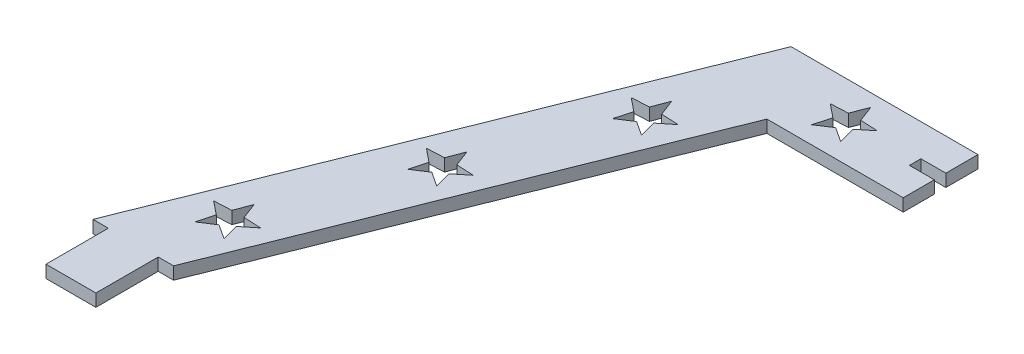
from build123d import *

# Parameters (mm, degrees)
BOSS_EXTRUDE1_DEPTH = 3.175


with BuildPart() as part:
    # Sketch1 → Boss-Extrude1 (new body)
    with BuildSketch(Plane(origin=(0, 0, 0), x_dir=(1, 0, 0), z_dir=(0, 1, 0))):
        Polygon((98.425, 127), (98.425, 118.8085), (92.075, 118.8085), (92.075, 115.8875), (98.425, 115.8875), (98.425, 107.95), (63.697477915, 107.95), (20.517477915, 0), (16.610957915, 0), (16.610957915, -15.875), (3.90652, -15.875), (3.90652, 0), (0, 0), (50.8, 127), align=None)
        Polygon((74.356304753, 123.754225326), (72.787834938, 119.633813496), (68.38440659, 119.415387337), (71.818467282, 116.65040662), (70.665468711, 112.395), (74.356304753, 114.806559768), (78.047140796, 112.395), (76.894142225, 116.65040662), (80.328202917, 119.415387337), (75.924774569, 119.633813496), align=None, mode=Mode.SUBTRACT)
        Polygon((47.649827384, 99.756946391), (46.081357569, 95.636534562), (41.67792922, 95.418108402), (45.111989912, 92.653127685), (43.958991341, 88.397721065), (47.649827384, 90.809280833), (51.340663426, 88.397721065), (50.187664855, 92.653127685), (53.621725547, 95.418108402), (49.218297199, 95.636534562), align=None, mode=Mode.SUBTRACT)
        Polygon((32.742653477, 62.489011624), (31.174183662, 58.368599795), (26.770755314, 58.150173636), (30.204816006, 55.385192919), (29.051817435, 51.129786299), (32.742653477, 53.541346066), (36.433489519, 51.129786299), (35.280490948, 55.385192919), (38.71455164, 58.150173636), (34.311123292, 58.368599795), align=None, mode=Mode.SUBTRACT)
        Polygon((17.261423317, 23.785936225), (15.692953502, 19.665524395), (11.289525154, 19.447098236), (14.723585846, 16.682117519), (13.570587275, 12.426710899), (17.261423317, 14.838270667), (20.952259359, 12.426710899), (19.799260788, 16.682117519), (23.23332148, 19.447098236), (18.829893132, 19.665524395), align=None, mode=Mode.SUBTRACT)
    extrude(amount=-BOSS_EXTRUDE1_DEPTH)


solid = part.part
